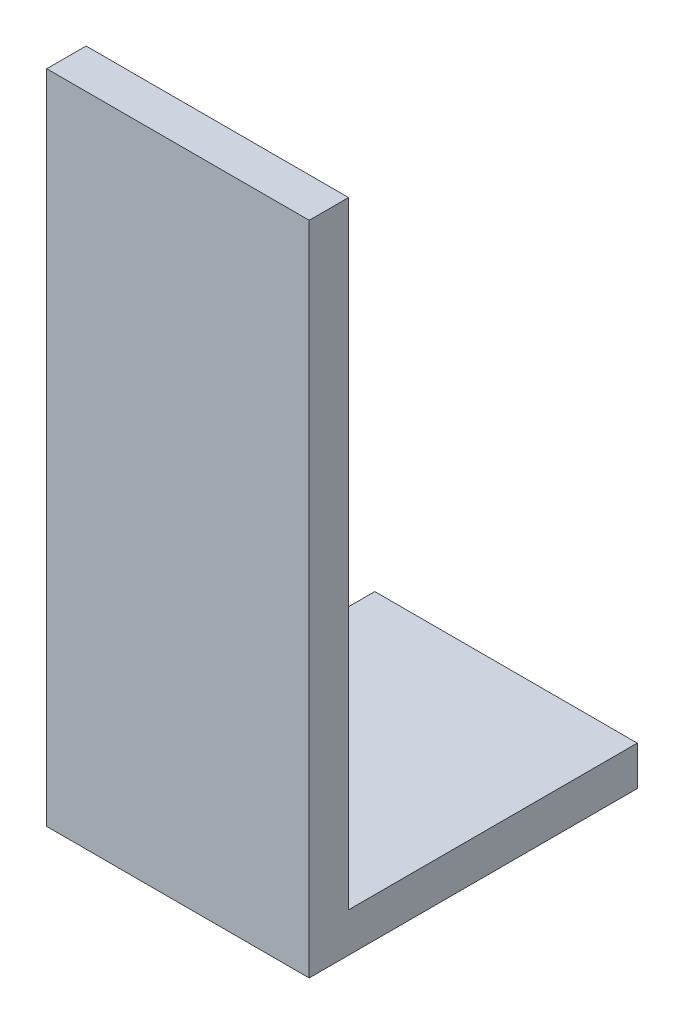
from build123d import *

# Parameters (mm, degrees)
SKETCH_1_W      = 3
SKETCH_1_H      = 47
SKETCH_1_H_2    = 3
SKETCH_1_W_2    = 22
EXTRUDE_1_DEPTH = 20


with BuildPart() as part:
    # ｽｹｯﾁ1 → ﾎﾞｽ - 押し出し1 (new body)
    with BuildSketch(Plane(origin=(0, 0, 0), x_dir=(0, 0, -1), z_dir=(1, 0, 0))):
        with Locations((1.5, 26.5)):
            Rectangle(SKETCH_1_W, SKETCH_1_H)
        with Locations((1.5, 1.5)):
            Rectangle(SKETCH_1_W, SKETCH_1_H_2)
        with Locations((14, 1.5)):
            Rectangle(SKETCH_1_W_2, SKETCH_1_H_2)
    extrude(amount=EXTRUDE_1_DEPTH)


solid = part.part
